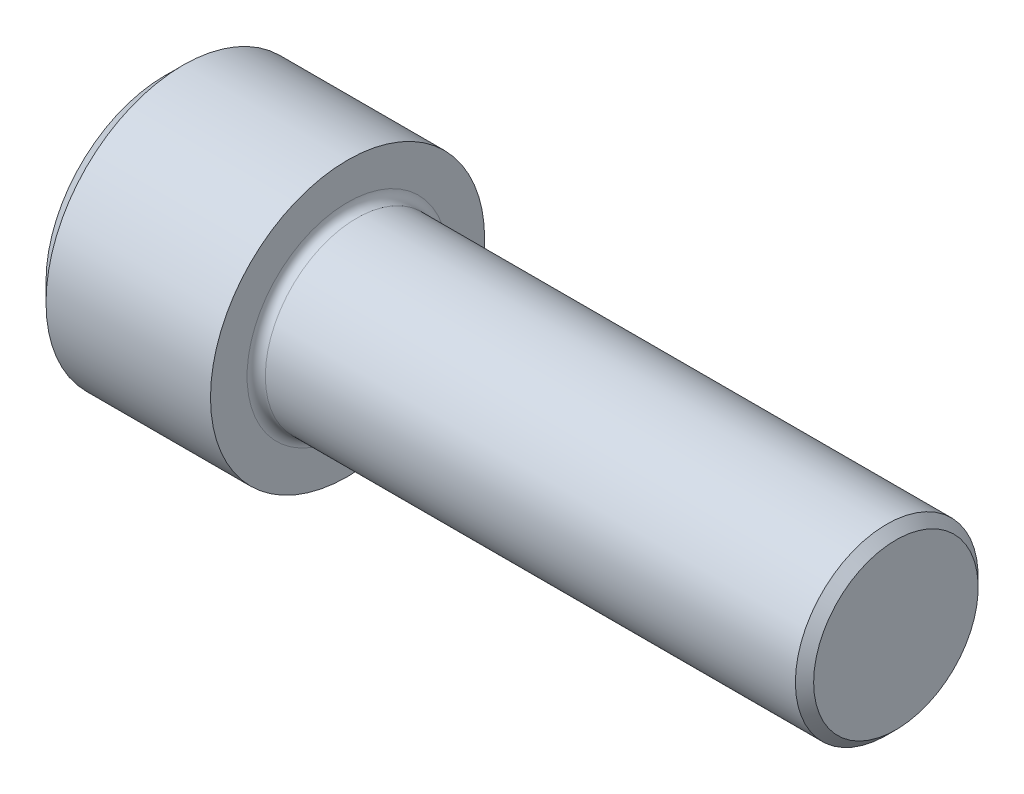
from build123d import *

# Parameters (mm, degrees)
FILLET1_R   = 1.27
HEX_2_DEPTH = 12.573


with BuildPart() as part:
    # BodySke → Base-Revolve (revolve)
    with BuildSketch(Plane.XY):
        Polygon((0, 0), (0, 16.51), (2.54, 19.05), (25.4, 19.05), (25.4, 12.7), (100.33127, 12.7), (101.6, 11.43127), (101.6, 0), align=None)
    revolve(axis=Axis((-31.75, 0, 0), (1, 0, 0)))

    # Fillet1
    fillet1_edges = [part.edges().sort_by_distance(p)[0] for p in [
        (25.4, -12.7, 0),
    ]]
    fillet(fillet1_edges, radius=FILLET1_R)

    # Sketch2 → Hex-PreBroach (revolve, cut)
    with BuildSketch(Plane.XY):
        Polygon((0, 9.525), (12.573, 9.525), (18.072261314, 0), (0, 0), align=None)
    revolve(axis=Axis((0, 0, 0), (1, 0, 0)), mode=Mode.SUBTRACT)

    # Sketch3 → Hex 2 (cut)
    with BuildSketch(Plane(origin=(0, 0, 0), x_dir=(0, 0.5, 0.866025404), z_dir=(-1, 0, 0))):
        Polygon((5.499261314, 9.525), (-5.499261314, 9.525), (-10.998522628, 0), (-5.499261314, -9.525), (5.499261314, -9.525), (10.998522628, 0), align=None)
    extrude(amount=-HEX_2_DEPTH, mode=Mode.SUBTRACT)


solid = part.part
